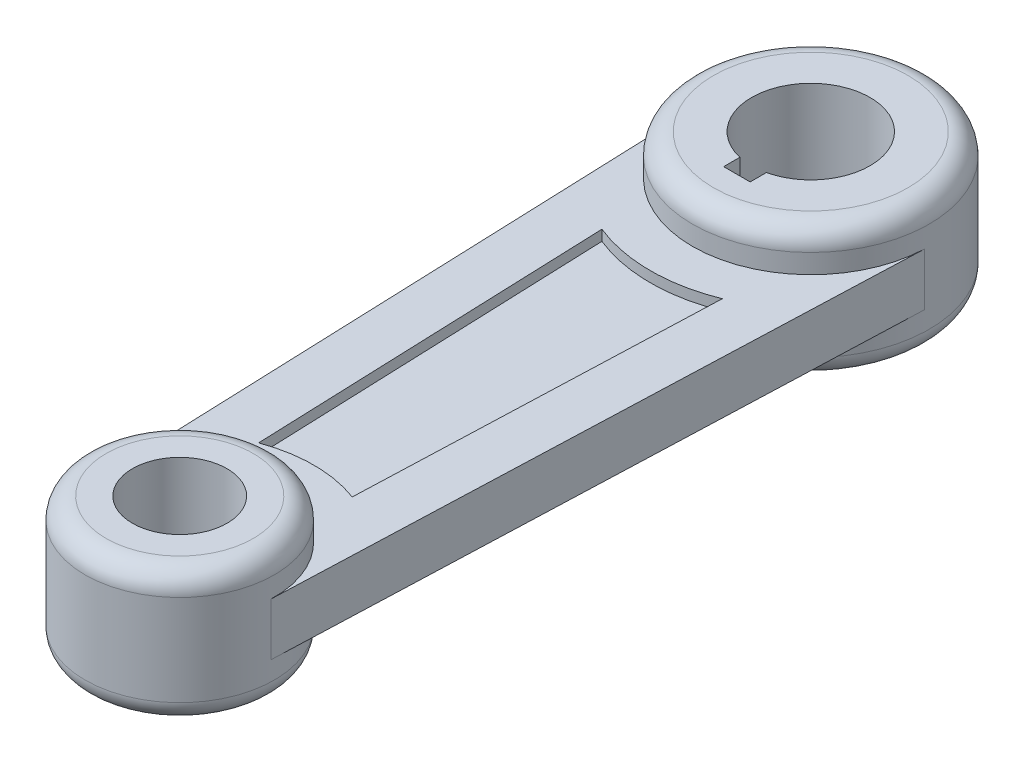
from build123d import *

# Parameters (mm, degrees)
SKETCH1_R             = 45
SKETCH1_R_2           = 22.5
BOSS_EXTRUDE1_DEPTH   = 31.65
SKETCH1_R_3           = 56.25
SKETCH1_R_4           = 28.15
BOSS_EXTRUDE1_2_DEPTH = 31.65
BOSS_EXTRUDE2_DEPTH   = 12.5
CUT_EXTRUDE1_DEPTH    = 5
CUT_EXTRUDE2_DEPTH    = 64.3
FILLET1_R             = 10


with BuildPart() as part:
    # Sketch1 → Boss-Extrude1 (new body, symmetric)
    with BuildSketch(Plane(origin=(0, 0, 0), x_dir=(1, 0, 0), z_dir=(0, 1, 0))):
        Circle(SKETCH1_R)
        Circle(SKETCH1_R_2, mode=Mode.SUBTRACT)
    extrude(amount=BOSS_EXTRUDE1_DEPTH, both=True)



with BuildPart() as body_2:
    # Sketch1 → Boss-Extrude1 2 (new body, symmetric)
    with BuildSketch(Plane(origin=(0, 0, 0), x_dir=(1, 0, 0), z_dir=(0, 1, 0))):
        with Locations((0, 300)):
            Circle(SKETCH1_R_3)
        with Locations((0, 300)):
            Circle(SKETCH1_R_4, mode=Mode.SUBTRACT)
    extrude(amount=BOSS_EXTRUDE1_2_DEPTH, both=True)


with BuildPart() as part_1:
    add(part.part)

    add(body_2.part)  # Boss-Extrude2 merges body 2
    # Sketch2 → Boss-Extrude2 (add, symmetric)
    with BuildSketch(Plane(origin=(0, 0, 0), x_dir=(1, 0, 0), z_dir=(0, 1, 0))):
        with BuildLine():
            Line((56.210435304, 297.890625), (44.968348244, -1.6875))
            ThreePointArc((44.968348244, -1.6875), (0, 45), (-44.968348244, -1.6875))
            Line((-44.968348244, -1.6875), (-56.210435304, 297.890625))
            ThreePointArc((-56.210435304, 297.890625), (0, 243.75), (56.210435304, 297.890625))
        make_face()
    extrude(amount=BOSS_EXTRUDE2_DEPTH, both=True)

    # Sketch3 → Cut-Extrude1 (cut)
    with BuildSketch(Plane(origin=(0, 12.5, 0), x_dir=(1, 0, 0), z_dir=(0, 1, 0))):
        with BuildLine():
            Line((22.255863805, 59.73892388), (28.619814412, 229.324907336))
            ThreePointArc((28.619814412, 229.324907336), (0, 223.75), (-28.619814412, 229.324907336))
            Line((-28.619814412, 229.324907336), (-22.255863805, 59.73892388))
            ThreePointArc((-22.255863805, 59.73892388), (0, 63.75), (22.255863805, 59.73892388))
        make_face()
    cut_extrude1 = extrude(amount=-CUT_EXTRUDE1_DEPTH, mode=Mode.SUBTRACT)

    # Mirror1: Cut-Extrude1 across plane
    add(cut_extrude1.mirror(Plane.ZX), mode=Mode.SUBTRACT)

    # Sketch4 → Cut-Extrude2 (cut, through all)
    with BuildSketch(Plane(origin=(0, 31.65, 0), x_dir=(1, 0, 0), z_dir=(0, 1, 0))):
        with BuildLine():
            Line((-6.3, 272.564029086), (-6.3, 264.864029086))
            Line((-6.3, 264.864029086), (6.3, 264.864029086))
            Line((6.3, 264.864029086), (6.3, 272.564029086))
            ThreePointArc((6.3, 272.564029086), (0, 328.15), (-6.3, 272.564029086))
        make_face()
    extrude(amount=-CUT_EXTRUDE2_DEPTH, mode=Mode.SUBTRACT)

    # Fillet1
    fillet1_edges = [part_1.edges().sort_by_distance(p)[0] for p in [
        (-45, -31.65, 0),
        (-56.25, 31.65, -300),
        (-56.25, -31.65, -300),
        (-45, 31.65, 0),
    ]]
    fillet(fillet1_edges, radius=FILLET1_R)


solid = part_1.part
